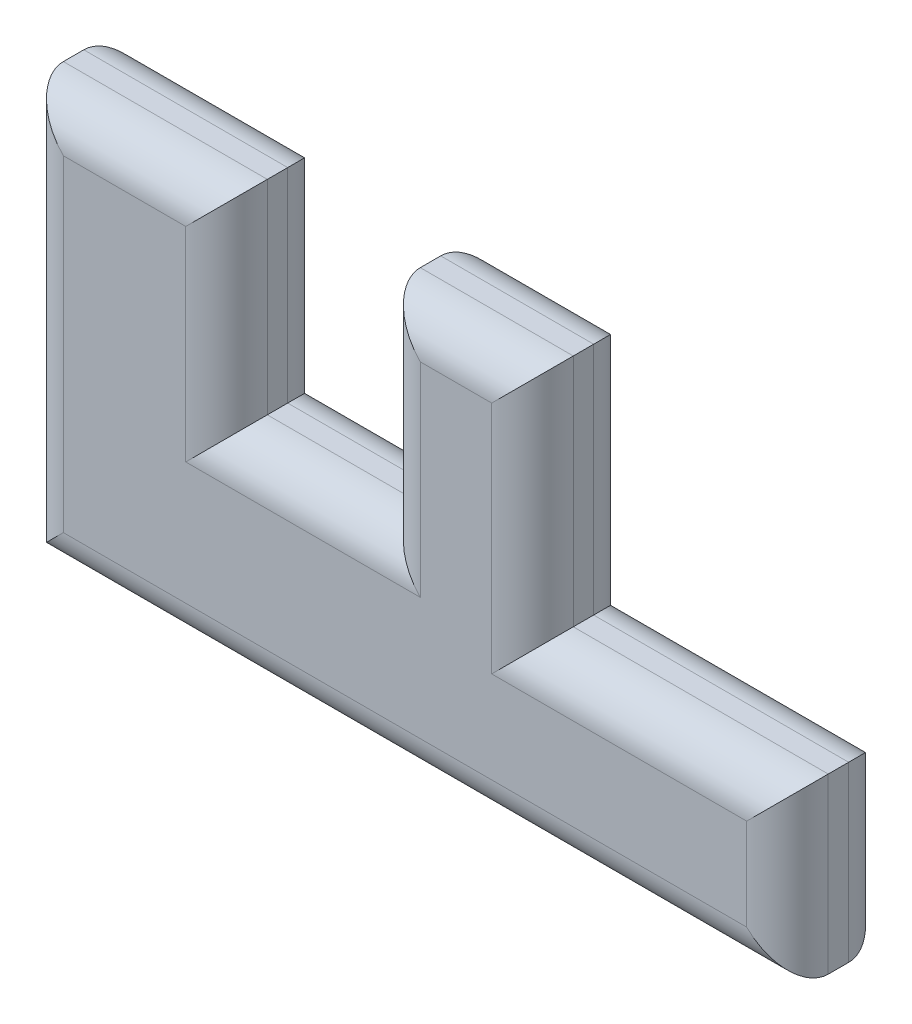
from build123d import *

# Parameters (mm, degrees)
BOSS_EXTRUDE1_DEPTH = 12.7
FILLET1_R           = 5.08


with BuildPart() as part:
    # Sketch3 → Boss-Extrude1 (new body)
    with BuildSketch(Plane.XY):
        Polygon((0, 0), (0, 50.8), (25.4, 50.8), (25.4, 25.4), (44.45, 25.4), (44.45, 50.8), (63.5, 50.8), (63.5, 21.59), (95.25, 21.59), (95.25, 0), align=None)
    extrude(amount=BOSS_EXTRUDE1_DEPTH)

    # Fillet1
    fillet1_edges = [part.edges().sort_by_distance(p)[0] for p in [
        (0, 25.4, 0),
        (12.7, 50.8, 0),
        (25.4, 38.1, 0),
        (34.925, 25.4, 0),
        (44.45, 38.1, 0),
        (53.975, 50.8, 0),
        (63.5, 36.195, 0),
        (79.375, 21.59, 12.7),
        (79.375, 21.59, 0),
        (95.25, 10.795, 0),
        (47.625, 0, 0),
        (63.5, 36.195, 12.7),
        (53.975, 50.8, 12.7),
        (44.45, 38.1, 12.7),
        (34.925, 25.4, 12.7),
        (25.4, 38.1, 12.7),
        (12.7, 50.8, 12.7),
        (0, 25.4, 12.7),
        (47.625, 0, 12.7),
        (95.25, 10.795, 12.7),
    ]]
    fillet(fillet1_edges, radius=FILLET1_R)


solid = part.part
